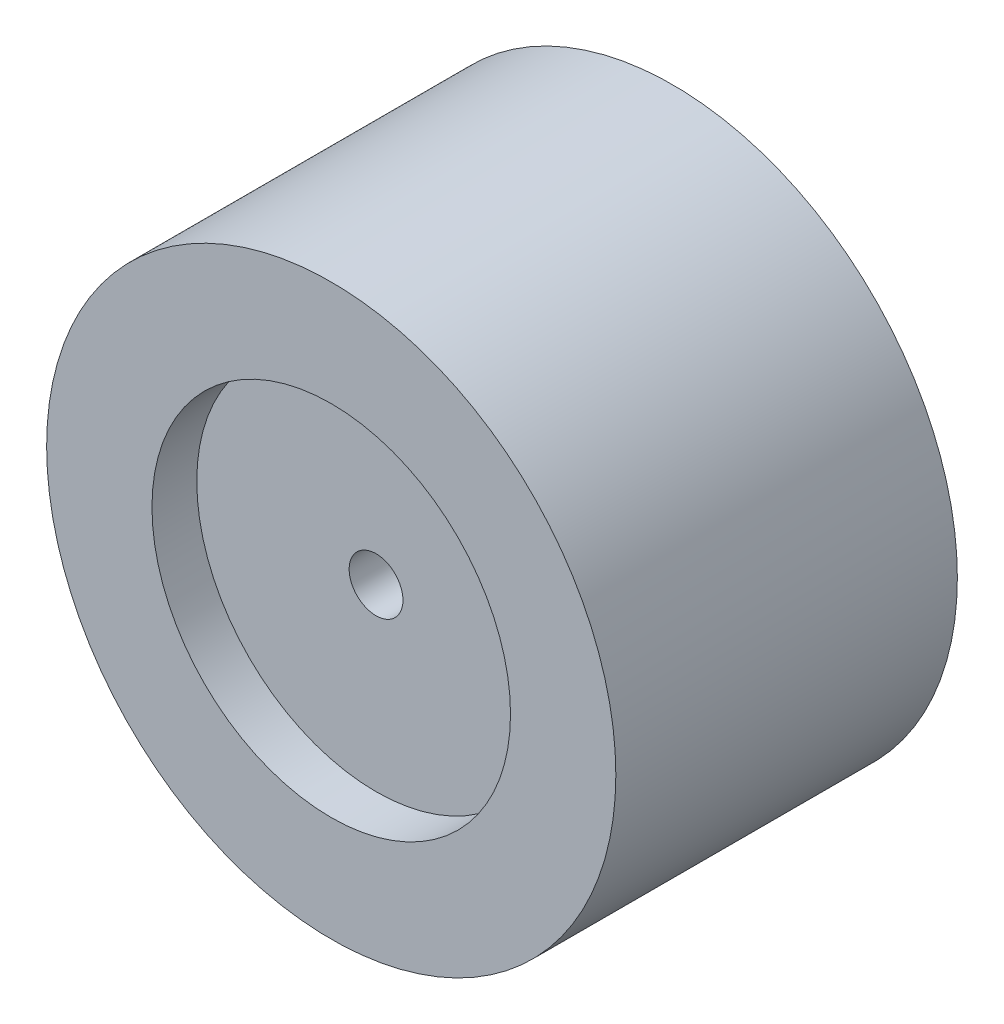
from build123d import *

# Parameters (mm, degrees)
ESQUISSE1_R             = 31.75
ESQUISSE1_R_2           = 3
BOSS_EXTRU_1_DEPTH      = 38.1
ESQUISSE2_R             = 20
ENL_V_MAT_EXTRU_1_DEPTH = 5


with BuildPart() as part:
    # Esquisse1 → Boss.-Extru.1 (new body)
    with BuildSketch(Plane.XY):
        Circle(ESQUISSE1_R)
        Circle(ESQUISSE1_R_2, mode=Mode.SUBTRACT)
    extrude(amount=BOSS_EXTRU_1_DEPTH)

    # Esquisse2 → Enlèv. mat.-Extru.1 (cut)
    with BuildSketch(Plane.XY.offset(38.1)):
        Circle(ESQUISSE2_R)
    extrude(amount=-ENL_V_MAT_EXTRU_1_DEPTH, mode=Mode.SUBTRACT)


solid = part.part
